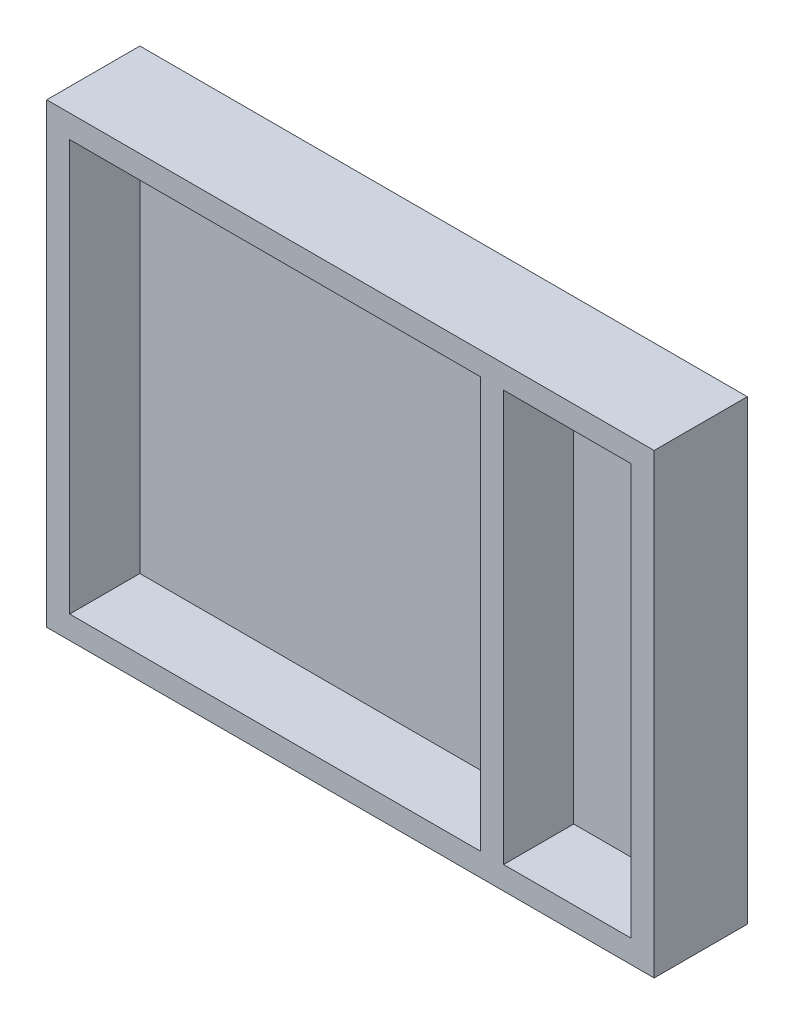
from build123d import *

# Parameters (mm, degrees)
SKETCH1_W           = 322
SKETCH1_H           = 322
SKETCH1_W_2         = 100
BOSS_EXTRUDE1_DEPTH = 55
SKETCH2_W           = 476
SKETCH2_H           = 358
BOSS_EXTRUDE2_DEPTH = 18


with BuildPart() as part:
    # Sketch1 → Boss-Extrude1 (new body)
    with BuildSketch(Plane.XY):
        Polygon((-18, -18), (340, -18), (458, -18), (458, 340), (340, 340), (-18, 340), align=None)
        with Locations((161, 161)):
            Rectangle(SKETCH1_W, SKETCH1_H, mode=Mode.SUBTRACT)
        with Locations((390, 161)):
            Rectangle(SKETCH1_W_2, SKETCH1_H, mode=Mode.SUBTRACT)
    extrude(amount=BOSS_EXTRUDE1_DEPTH)

    # Sketch2 → Boss-Extrude2 (add)
    with BuildSketch(Plane(origin=(0, 0, 0), x_dir=(-1, 0, 0), z_dir=(0, 0, -1))):
        with Locations((-220, 161)):
            Rectangle(SKETCH2_W, SKETCH2_H)
    extrude(amount=BOSS_EXTRUDE2_DEPTH)


solid = part.part
